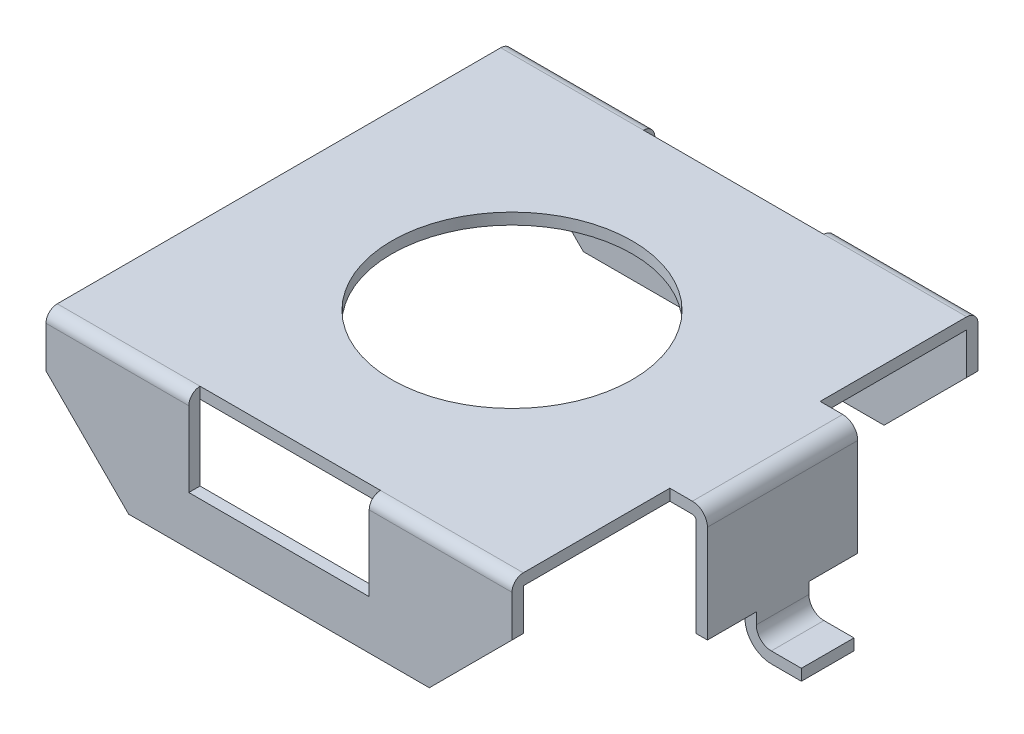
from build123d import *

# Parameters (mm, degrees)
EXTRUDE_THIN3_DEPTH     = 3.1
SKETCH2_W               = 2.4
SKETCH2_H               = 1
CUT_EXTRUDE1_DEPTH      = 4.1
CUT_EXTRUDE1_DEPTH_BACK = 4.1
SKETCH3_W               = 2.4
SKETCH3_H               = 0.15
CUT_EXTRUDE2_DEPTH      = 1
FILLET1_R               = 0.15
SKETCH4_R               = 1.6
CUT_EXTRUDE3_DEPTH      = 1
EXTRUDE_THIN4_DEPTH     = 1
SKETCH6_W               = 1
SKETCH6_H               = 0.65
CUT_EXTRUDE4_DEPTH      = 0.5


with BuildPart() as part:
    # Sketch1 → Extrude-Thin3 (new body, symmetric)
    with BuildSketch(Plane(origin=(0, 0, 0), x_dir=(0, 0, -1), z_dir=(1, 0, 0))):
        Polygon((-3.1, 0.2), (-3.1, 2), (3.1, 2), (3.1, 0.2), (2.95, 0.2), (2.95, 1.85), (-2.95, 1.85), (-2.95, 0.2), align=None)
    extrude(amount=EXTRUDE_THIN3_DEPTH, both=True)

    # Sketch2 → Cut-Extrude1 (cut, two sides)
    with BuildSketch(Plane.XY) as cut_extrude1_sk:
        with Locations((0, 1.35)):
            Rectangle(SKETCH2_W, SKETCH2_H)
        Polygon((-3.1, 1.3), (-2, 0.2), (-3.1, 0.2), align=None)
        Polygon((3.1, 0.2), (3.1, 1.3), (2, 0.2), align=None)
    extrude(amount=CUT_EXTRUDE1_DEPTH, mode=Mode.SUBTRACT)
    extrude(cut_extrude1_sk.sketch, amount=-CUT_EXTRUDE1_DEPTH_BACK, mode=Mode.SUBTRACT)

    # Sketch3 → Cut-Extrude2 (cut)
    with BuildSketch(Plane(origin=(0, 2, 0), x_dir=(1, 0, 0), z_dir=(0, 1, 0))):
        with Locations((0, 3.025)):
            Rectangle(SKETCH3_W, SKETCH3_H)
        with Locations((0, -3.025)):
            Rectangle(SKETCH3_W, SKETCH3_H)
    extrude(amount=-CUT_EXTRUDE2_DEPTH, mode=Mode.SUBTRACT)

    # Fillet1
    fillet1_edges = [part.edges().sort_by_distance(p)[0] for p in [
        (-2.15, 2, -3.1),
        (2.15, 2, -3.1),
        (-2.15, 2, 3.1),
        (2.15, 2, 3.1),
    ]]
    fillet(fillet1_edges, radius=FILLET1_R)

    # Sketch4 → Cut-Extrude3 (cut)
    with BuildSketch(Plane(origin=(0, 2, 0), x_dir=(1, 0, 0), z_dir=(0, 1, 0))):
        Circle(SKETCH4_R)
    extrude(amount=-CUT_EXTRUDE3_DEPTH, mode=Mode.SUBTRACT)

    # Sketch5 → Extrude-Thin4 (add, symmetric)
    with BuildSketch(Plane.XY):
        with BuildLine():
            Line((3.1, 2), (3.4, 2))
            ThreePointArc((3.4, 2), (3.541421356, 1.941421356), (3.6, 1.8))
            Line((3.6, 1.8), (3.6, 0.35))
            ThreePointArc((3.6, 0.35), (3.658578644, 0.208578644), (3.8, 0.15))
            Line((3.8, 0.15), (4.2, 0.15))
            Line((4.2, 0.15), (4.2, 0))
            Line((4.2, 0), (3.8, 0))
            ThreePointArc((3.8, 0), (3.552512627, 0.102512627), (3.45, 0.35))
            Line((3.45, 0.35), (3.45, 1.8))
            ThreePointArc((3.45, 1.8), (3.435355339, 1.835355339), (3.4, 1.85))
            Line((3.4, 1.85), (3.1, 1.85))
            Line((3.1, 1.85), (3.1, 2))
        make_face()
    extrude(amount=EXTRUDE_THIN4_DEPTH, both=True)

    # Sketch6 → Cut-Extrude4 (cut)
    with BuildSketch(Plane.XZ):
        with Locations((3.7, 0.675)):
            Rectangle(SKETCH6_W, SKETCH6_H)
        with Locations((3.7, -0.675)):
            Rectangle(SKETCH6_W, SKETCH6_H)
    extrude(amount=-CUT_EXTRUDE4_DEPTH, mode=Mode.SUBTRACT)


solid = part.part
